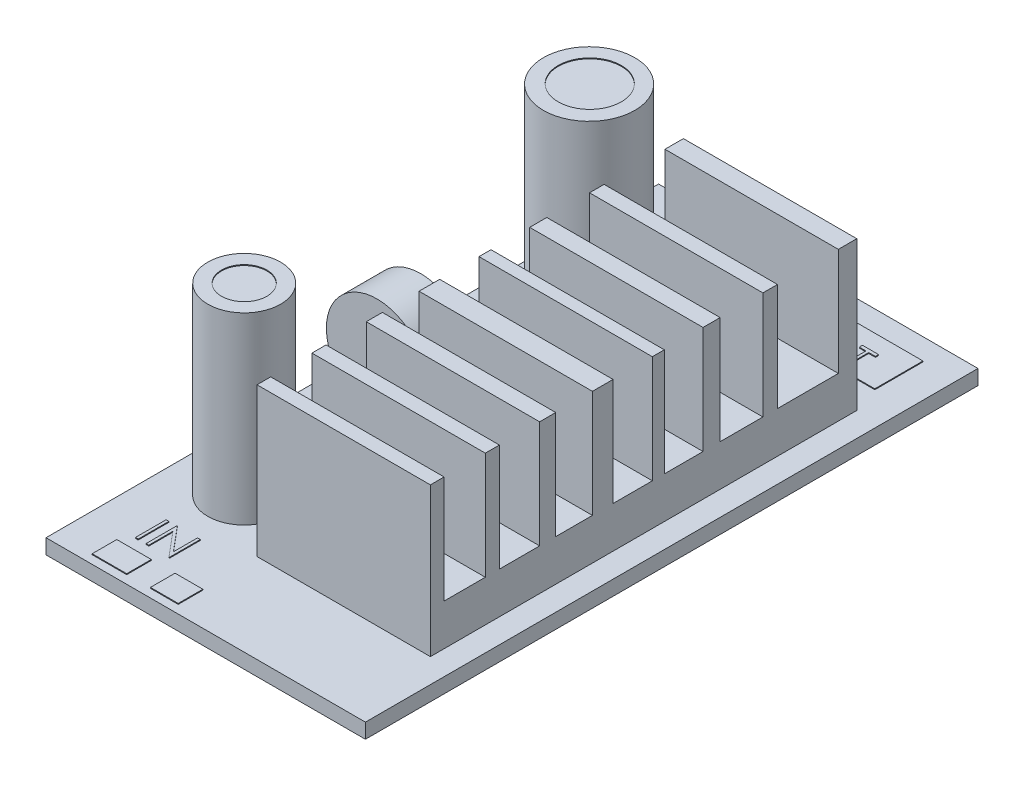
from build123d import *

# Parameters (mm, degrees)
SKETCH1_W            = 36.5
SKETCH1_H            = 70
BOSS_EXTRUDE1_DEPTH  = 1.7
SKETCH2_W            = 19.810620686
SKETCH2_H            = 48.723418446
BOSS_EXTRUDE2_DEPTH  = 17
SKETCH3_W            = 6.953051931
SKETCH3_H            = 17.871067358
SKETCH3_W_2          = 4.884375323
SKETCH3_W_3          = 4.424669411
SKETCH3_W_4          = 4.492569906
SKETCH3_W_5          = 4.194816454
SKETCH3_W_6          = 4.597059127
SKETCH3_W_7          = 4.711985605
CUT_EXTRUDE1_DEPTH   = 28
SKETCH4_R            = 5.221404291
SKETCH4_R_2          = 4.164394739
BOSS_EXTRUDE3_DEPTH  = 21
SKETCH5_R            = 3.607238236
SKETCH5_R_2          = 2.597429553
CUT_EXTRUDE2_DEPTH   = 0.1
SKETCH6_W            = 3.944670861
SKETCH6_H            = 4.098359336
SKETCH6_W_2          = 3.739752895
SKETCH6_H_2          = 4.098359337
SKETCH6_H_3          = 2.810169011
SKETCH6_W_3          = 3.171545661
BOSS_EXTRUDE4_DEPTH  = 0.1
SKETCH7_W            = 0.314102564
SKETCH7_H            = 3.5
BOSS_EXTRUDE5_DEPTH  = 0.1
BOSS_EXTRUDE6_DEPTH  = 0.1
SKETCH9_W            = 13.236826134
SKETCH9_H            = 5.502950191
BOSS_EXTRUDE7_DEPTH  = 0.1
BOSS_EXTRUDE8_DEPTH  = 0.1
BOSS_EXTRUDE10_DEPTH = 5


with BuildPart() as part:
    # Sketch1 → Boss-Extrude1 (new body)
    with BuildSketch(Plane(origin=(0, 0, 0), x_dir=(1, 0, 0), z_dir=(0, 1, 0))):
        with Locations((-3.148767606, -0.556338028)):
            Rectangle(SKETCH1_W, SKETCH1_H)
    extrude(amount=BOSS_EXTRUDE1_DEPTH)

    # Sketch2 → Boss-Extrude2 (add)
    with BuildSketch(Plane(origin=(0, 1.7, 0), x_dir=(1, 0, 0), z_dir=(0, 1, 0))):
        with Locations((2.428546777, -1.002523179)):
            Rectangle(SKETCH2_W, SKETCH2_H)
    extrude(amount=BOSS_EXTRUDE2_DEPTH)

    # Sketch3 → Cut-Extrude1 (cut)
    with BuildSketch(Plane.ZY.offset(7.476763566)):
        with Locations((-17.774435243, 15.354908485)):
            Rectangle(SKETCH3_W, SKETCH3_H)
        with Locations((-10.189287682, 15.354908485)):
            Rectangle(SKETCH3_W_2, SKETCH3_H)
        with Locations((-3.581015187, 15.354908485)):
            Rectangle(SKETCH3_W_3, SKETCH3_H)
        with Locations((2.246284953, 15.354908485)):
            Rectangle(SKETCH3_W_4, SKETCH3_H)
        with Locations((8.945970936, 15.354908485)):
            Rectangle(SKETCH3_W_5, SKETCH3_H)
        with Locations((15.180732378, 15.354908485)):
            Rectangle(SKETCH3_W_6, SKETCH3_H)
        with Locations((21.444225439, 15.354908485)):
            Rectangle(SKETCH3_W_7, SKETCH3_H)
    extrude(amount=-CUT_EXTRUDE1_DEPTH, mode=Mode.SUBTRACT)

    # Sketch4 → Boss-Extrude3 (add)
    with BuildSketch(Plane(origin=(0, 1.7, 0), x_dir=(1, 0, 0), z_dir=(0, 1, 0))):
        with Locations((-14.266214275, 19.373265365)):
            Circle(SKETCH4_R)
        with Locations((-14.266214275, -20.039756271)):
            Circle(SKETCH4_R_2)
    extrude(amount=BOSS_EXTRUDE3_DEPTH)

    # Sketch5 → Cut-Extrude2 (cut)
    with BuildSketch(Plane(origin=(0, 22.7, 0), x_dir=(1, 0, 0), z_dir=(0, 1, 0))):
        with Locations((-14.266214275, 19.447629557)):
            Circle(SKETCH5_R)
        with Locations((-14.266214275, -20.039756271)):
            Circle(SKETCH5_R_2)
    extrude(amount=-CUT_EXTRUDE2_DEPTH, mode=Mode.SUBTRACT)

    # Sketch6 → Boss-Extrude4 (add)
    with BuildSketch(Plane(origin=(0, 1.7, 0), x_dir=(1, 0, 0), z_dir=(0, 1, 0))):
        with Locations((-15.10212375, 30.400788251)):
            Rectangle(SKETCH6_W, SKETCH6_H)
        with Locations((-8.54474881, 30.298329268)):
            Rectangle(SKETCH6_W_2, SKETCH6_H_2)
        with Locations((-15.10212375, -33.198217184)):
            Rectangle(SKETCH6_W, SKETCH6_H_3)
        with Locations((-8.828852428, -33.198217184)):
            Rectangle(SKETCH6_W_3, SKETCH6_H_3)
    extrude(amount=BOSS_EXTRUDE4_DEPTH)

    # Sketch7 → Boss-Extrude5 (add)
    with BuildSketch(Plane(origin=(0, 1.7, 0), x_dir=(1, 0, 0), z_dir=(0, 1, 0))):
        with Locations((-16.057613637, -28.766806996)):
            Rectangle(SKETCH7_W, SKETCH7_H)
        Polygon((-15.003126458, -30.516806996), (-15.003126458, -27.016806996), (-14.937221009, -27.016806996), (-12.62492133, -29.771514528), (-12.62492133, -27.016806996), (-12.310818765, -27.016806996), (-12.310818765, -30.516806996), (-12.382333188, -30.516806996), (-14.689023894, -27.76840956), (-14.689023894, -30.516806996), align=None)
    extrude(amount=BOSS_EXTRUDE5_DEPTH)

    # Sketch8 → Boss-Extrude6 (add)
    with BuildSketch(Plane(origin=(0, 1.7, 0), x_dir=(1, 0, 0), z_dir=(0, 1, 0))):
        with BuildLine():
            add(Edge.make_bspline(
                [(-15.055999829, 28.184413247), (-14.991191723, 28.182771767), (-14.863903256, 28.179547766), (-14.676828359, 28.154868663), (-14.498233263, 28.112173273), (-14.326663124, 28.05531029), (-14.164170148, 27.979455905), (-14.009531255, 27.887770757), (-13.863114382, 27.779294298), (-13.726893, 27.654865071), (-13.60223605, 27.519481617), (-13.492410164, 27.375003707), (-13.40036787, 27.222304905), (-13.324782083, 27.061844074), (-13.265483473, 26.893984106), (-13.224564429, 26.717830103), (-13.198426279, 26.534523413), (-13.195370502, 26.409496549), (-13.193820342, 26.3460719)],
                knots=[0, 0, 0, 0, 0.000194393, 0.000381804, 0.00056479, 0.000744601, 0.000923091, 0.001101652, 0.001283106, 0.001468738, 0.001654324, 0.001834514, 0.002012231, 0.002188181, 0.002365797, 0.002545211, 0.002729936, 0.002920126, 0.002920126, 0.002920126, 0.002920126], degree=3))
            add(Edge.make_bspline(
                [(-13.193820342, 26.3460719), (-13.195370275, 26.283114454), (-13.198425371, 26.159018034), (-13.224594149, 25.976874589), (-13.265635149, 25.801783893), (-13.324231415, 25.63403824), (-13.399456893, 25.473460676), (-13.492112064, 25.320473723), (-13.601253275, 25.175027224), (-13.725460126, 25.038714559), (-13.860861168, 24.913717088), (-14.006091435, 24.804798213), (-14.157884755, 24.711074088), (-14.318194463, 24.636290414), (-14.4848945, 24.576518494), (-14.659476823, 24.535765864), (-14.841123377, 24.50947882), (-14.964994381, 24.506460304), (-15.027954957, 24.504926067)],
                knots=[0, 0, 0, 0, 0.000188789, 0.000372126, 0.000550857, 0.00072758, 0.000904164, 0.001081881, 0.001263191, 0.001448823, 0.00163441, 0.001815159, 0.001992641, 0.002168591, 0.002344885, 0.002522934, 0.002705576, 0.002894365, 0.002894365, 0.002894365, 0.002894365], degree=3))
            add(Edge.make_bspline(
                [(-15.027954957, 24.504926067), (-15.091379276, 24.506475454), (-15.216405492, 24.509529708), (-15.399942528, 24.535711113), (-15.576220272, 24.576652416), (-15.744734623, 24.635161853), (-15.905579552, 24.710779083), (-16.059069635, 24.802983462), (-16.204588782, 24.912390604), (-16.340930529, 25.036557178), (-16.465679727, 25.17172873), (-16.574439103, 25.316562985), (-16.666664216, 25.468218442), (-16.742027548, 25.627115966), (-16.801692008, 25.792487409), (-16.842396826, 25.965435886), (-16.868732778, 26.144975392), (-16.871767624, 26.26721829), (-16.873307521, 26.329244977)],
                knots=[0, 0, 0, 0, 0.00019019, 0.000374915, 0.000555011, 0.000732396, 0.00090898, 0.001087298, 0.001268608, 0.00145424, 0.001639827, 0.001819595, 0.001996712, 0.002171394, 0.002346367, 0.002523053, 0.002703612, 0.002889599, 0.002889599, 0.002889599, 0.002889599], degree=3))
            add(Edge.make_bspline(
                [(-16.873307521, 26.329244977), (-16.872772886, 26.370877646), (-16.87171036, 26.45361777), (-16.858918667, 26.57648437), (-16.840356966, 26.697375028), (-16.813755053, 26.815945976), (-16.778963386, 26.931906961), (-16.737911359, 27.046057723), (-16.687771514, 27.157241447), (-16.631090866, 27.265984839), (-16.567829058, 27.370592745), (-16.497953308, 27.469472328), (-16.42391794, 27.563453325), (-16.342754546, 27.650100328), (-16.257138101, 27.731933985), (-16.165679723, 27.807696702), (-16.068937478, 27.878071653), (-15.966495099, 27.941491994), (-15.860876824, 27.998851129), (-15.752000046, 28.04807298), (-15.641343474, 28.090319041), (-15.528388827, 28.124559866), (-15.413436054, 28.151591902), (-15.29623427, 28.169999256), (-15.176876844, 28.182823574), (-15.096465525, 28.183881076), (-15.055999829, 28.184413247)],
                knots=[0, 0, 0, 0, 0.000124849, 0.000248123, 0.000370193, 0.00049164, 0.000612319, 0.000733199, 0.000855287, 0.000977905, 0.001100913, 0.001221706, 0.001340948, 0.001459521, 0.001577551, 0.001696047, 0.001815534, 0.001936153, 0.002057243, 0.002175846, 0.002294342, 0.002412335, 0.002529682, 0.00264829, 0.002768075, 0.00288942, 0.00288942, 0.00288942, 0.00288942], degree=3))
        make_face()
        with BuildLine():
            add(Edge.make_bspline(
                [(-15.04057515, 27.825438888), (-15.073789783, 27.825033997), (-15.139901516, 27.824228088), (-15.238186052, 27.813612372), (-15.335177986, 27.798482483), (-15.430897348, 27.776900962), (-15.524943638, 27.74749691), (-15.618193479, 27.713656001), (-15.709796533, 27.672434911), (-15.799450391, 27.625862206), (-15.886365466, 27.574313286), (-15.968378167, 27.517341519), (-16.045700811, 27.456282964), (-16.118144078, 27.390995127), (-16.18549525, 27.321145525), (-16.249079952, 27.247793089), (-16.306349533, 27.168841198), (-16.35883511, 27.086430791), (-16.40580295, 27.00066921), (-16.447568305, 26.912459348), (-16.481732314, 26.821081661), (-16.50959469, 26.727527503), (-16.532694501, 26.631945044), (-16.547328425, 26.533609195), (-16.558060784, 26.433014083), (-16.55882063, 26.365032229), (-16.559204957, 26.330647221)],
                knots=[0, 0, 0, 0, 9.9599e-05, 0.000198245, 0.000296222, 0.00039402, 0.00049227, 0.000591646, 0.000691452, 0.000793368, 0.000894612, 0.000994383, 0.001092713, 0.00119001, 0.001286696, 0.001383657, 0.001480979, 0.001579008, 0.001676595, 0.001774142, 0.001871547, 0.001968922, 0.002066879, 0.00216624, 0.00226698, 0.002370083, 0.002370083, 0.002370083, 0.002370083], degree=3))
            add(Edge.make_bspline(
                [(-16.559204957, 26.330647221), (-16.557930095, 26.280085), (-16.555422048, 26.18061347), (-16.533464477, 26.034845326), (-16.499642503, 25.89475704), (-16.449785137, 25.76111513), (-16.387434522, 25.632770848), (-16.310407632, 25.510862743), (-16.219148546, 25.395357868), (-16.115485019, 25.2870626), (-16.002162313, 25.188216795), (-15.881829583, 25.101453387), (-15.755775975, 25.028043137), (-15.623672773, 24.968238064), (-15.486225234, 24.920848327), (-15.342547683, 24.888369695), (-15.193597223, 24.86699424), (-15.092066568, 24.864941484), (-15.04057515, 24.863900426)],
                knots=[0, 0, 0, 0, 0.000151605, 0.000298253, 0.000441263, 0.000583229, 0.000725274, 0.000868635, 0.001014928, 0.001166177, 0.001317744, 0.00146543, 0.001610576, 0.001754594, 0.001899821, 0.002045914, 0.002195936, 0.002350312, 0.002350312, 0.002350312, 0.002350312], degree=3))
            add(Edge.make_bspline(
                [(-15.04057515, 24.863900426), (-15.005965648, 24.86437593), (-14.937324612, 24.865318998), (-14.835229089, 24.874817675), (-14.734972878, 24.890049545), (-14.636696598, 24.9119802), (-14.540511786, 24.939427407), (-14.446016983, 24.972035135), (-14.354218693, 25.012716338), (-14.263958855, 25.05766429), (-14.177562613, 25.108904447), (-14.095087081, 25.163942597), (-14.018611101, 25.224911218), (-13.94622203, 25.28922903), (-13.878594341, 25.358192878), (-13.816185357, 25.4317131), (-13.759205224, 25.510253757), (-13.706739578, 25.592539163), (-13.659936315, 25.678535416), (-13.619157216, 25.767065094), (-13.5845611, 25.857910203), (-13.556632595, 25.951201775), (-13.534747134, 26.046762623), (-13.519667214, 26.144720701), (-13.509118775, 26.244880044), (-13.508323698, 26.3126239), (-13.507922906, 26.346773022)],
                knots=[0, 0, 0, 0, 0.000103804, 0.000205874, 0.000307314, 0.000407849, 0.000507719, 0.000607281, 0.000707445, 0.000808723, 0.000909609, 0.001008589, 0.001105934, 0.001202762, 0.001298946, 0.001395452, 0.001491794, 0.001589823, 0.001688026, 0.001785277, 0.001882027, 0.001979402, 0.0020772, 0.002175869, 0.002276609, 0.002379011, 0.002379011, 0.002379011, 0.002379011], degree=3))
            add(Edge.make_bspline(
                [(-13.507922906, 26.346773022), (-13.508324019, 26.380688527), (-13.509119701, 26.447966177), (-13.519662175, 26.547426995), (-13.534763066, 26.644680207), (-13.556525774, 26.73934401), (-13.584575927, 26.831442535), (-13.619163258, 26.920889282), (-13.659948557, 27.008017477), (-13.706756782, 27.092611774), (-13.759372605, 27.173786512), (-13.816866848, 27.251388925), (-13.880232196, 27.323961666), (-13.947658221, 27.39329636), (-14.020829107, 27.45791425), (-14.099413401, 27.51783677), (-14.182457079, 27.574510045), (-14.270384314, 27.625635607), (-14.361128268, 27.672849839), (-14.454242226, 27.713300842), (-14.548671325, 27.747672962), (-14.644175438, 27.776989927), (-14.741558416, 27.798397957), (-14.840162245, 27.813626007), (-14.939850503, 27.824224393), (-15.006893723, 27.825032771), (-15.04057515, 27.825438888)],
                knots=[0, 0, 0, 0, 0.000101701, 0.000201743, 0.00029972, 0.000396835, 0.000492868, 0.000588308, 0.000684288, 0.000781261, 0.000878109, 0.000974304, 0.001070733, 0.001166917, 0.001264269, 0.001363274, 0.001463228, 0.001565678, 0.001668217, 0.001769947, 0.001869982, 0.001969573, 0.002069423, 0.002168785, 0.002268827, 0.002369827, 0.002369827, 0.002369827, 0.002369827], degree=3))
        make_face(mode=Mode.SUBTRACT)
        with BuildLine():
            Line((-12.475871624, 28.094669657), (-12.16176906, 28.094669657))
            Line((-12.16176906, 28.094669657), (-12.16176906, 25.997614368))
            add(Edge.make_bspline(
                [(-12.16176906, 25.997614368), (-12.161815804, 25.967933633), (-12.161904509, 25.911609322), (-12.161311995, 25.831441021), (-12.159652626, 25.760168562), (-12.158606467, 25.697517215), (-12.156279133, 25.643774467), (-12.154381086, 25.598649156), (-12.15194053, 25.562354954), (-12.149007412, 25.541174028), (-12.147746624, 25.532069497)],
                knots=[0, 0, 0, 0, 8.9042e-05, 0.000168973, 0.000240502, 0.000302917, 0.000356945, 0.000401866, 0.000438432, 0.000465999, 0.000465999, 0.000465999, 0.000465999], degree=3))
            add(Edge.make_bspline(
                [(-12.147746624, 25.532069497), (-12.142569165, 25.499222733), (-12.132505979, 25.435380004), (-12.106859601, 25.344471722), (-12.0710421, 25.262540264), (-12.028599057, 25.187028973), (-11.972666446, 25.120039613), (-11.905662911, 25.05832796), (-11.824485142, 25.004356155), (-11.734224537, 24.955005344), (-11.636939299, 24.915340261), (-11.537528033, 24.885346897), (-11.437485054, 24.867067997), (-11.370508888, 24.864951458), (-11.337249829, 24.863900426)],
                knots=[0, 0, 0, 0, 9.971e-05, 0.000193801, 0.000282365, 0.000367504, 0.000452699, 0.000543015, 0.000639862, 0.000744331, 0.000851226, 0.000954377, 0.001055468, 0.001155185, 0.001155185, 0.001155185, 0.001155185], degree=3))
            add(Edge.make_bspline(
                [(-11.337249829, 24.863900426), (-11.308696089, 24.864974276), (-11.251753527, 24.867115775), (-11.167147096, 24.880377206), (-11.084746988, 24.904277771), (-11.004146308, 24.93511753), (-10.928595323, 24.975865121), (-10.858051881, 25.02293596), (-10.795087947, 25.078146836), (-10.737629949, 25.139247181), (-10.687595013, 25.208186981), (-10.644223872, 25.283465119), (-10.608697942, 25.366214466), (-10.591154417, 25.424368888), (-10.582141656, 25.454244977)],
                knots=[0, 0, 0, 0, 8.5678e-05, 0.00017086, 0.000256092, 0.000342674, 0.000429242, 0.000513055, 0.000596556, 0.000679898, 0.000764179, 0.00085149, 0.000940054, 0.001033621, 0.001033621, 0.001033621, 0.001033621], degree=3))
            add(Edge.make_bspline(
                [(-10.582141656, 25.454244977), (-10.579141531, 25.466593552), (-10.572456043, 25.494111152), (-10.566208998, 25.540632442), (-10.559702472, 25.595521806), (-10.555187902, 25.659173619), (-10.550786682, 25.731374592), (-10.548153609, 25.812500849), (-10.546936576, 25.90225781), (-10.546573896, 25.964894972), (-10.546384445, 25.997614368)],
                knots=[0, 0, 0, 0, 3.81e-05, 8.4902e-05, 0.000140649, 0.000203941, 0.000276279, 0.000357657, 0.000447412, 0.000545571, 0.000545571, 0.000545571, 0.000545571], degree=3))
            Line((-10.546384445, 25.997614368), (-10.546384445, 28.094669657))
            Line((-10.546384445, 28.094669657), (-10.23228188, 28.094669657))
            Line((-10.23228188, 28.094669657), (-10.23228188, 25.980787445))
            add(Edge.make_bspline(
                [(-10.23228188, 25.980787445), (-10.232536001, 25.942689066), (-10.233031932, 25.868337763), (-10.237332509, 25.759386404), (-10.244189509, 25.656033423), (-10.253877597, 25.558264927), (-10.2667146, 25.466430767), (-10.28098982, 25.379725999), (-10.299169353, 25.298773007), (-10.320402754, 25.222940589), (-10.344676302, 25.150755075), (-10.376117451, 25.082246461), (-10.411541951, 25.015332061), (-10.453556604, 24.951023952), (-10.500767986, 24.889037399), (-10.554219667, 24.829748324), (-10.612143828, 24.772209278), (-10.675503388, 24.717896212), (-10.743253913, 24.668087535), (-10.81519387, 24.624289764), (-10.89077064, 24.587266146), (-10.969787766, 24.556790222), (-11.052278969, 24.533875623), (-11.138246329, 24.516800467), (-11.227885522, 24.507098169), (-11.288850178, 24.505656239), (-11.319721784, 24.504926067)],
                knots=[0, 0, 0, 0, 0.000114291, 0.000223047, 0.000327049, 0.000424998, 0.000517708, 0.000605194, 0.000688542, 0.000766455, 0.0008414, 0.000916717, 0.000992315, 0.001068354, 0.001146882, 0.001225836, 0.001307639, 0.001391671, 0.001475952, 0.001559641, 0.001643989, 0.001728103, 0.001813335, 0.001900511, 0.00199079, 0.002083404, 0.002083404, 0.002083404, 0.002083404], degree=3))
            add(Edge.make_bspline(
                [(-11.319721784, 24.504926067), (-11.353390887, 24.505710832), (-11.419449546, 24.507250539), (-11.516787613, 24.516073289), (-11.610101809, 24.532691683), (-11.700377686, 24.553851627), (-11.786386184, 24.583035364), (-11.869279628, 24.617133489), (-11.947638309, 24.65901075), (-12.022733438, 24.705604143), (-12.092558194, 24.758028781), (-12.156655597, 24.815168955), (-12.215131467, 24.876109332), (-12.267000164, 24.941509698), (-12.313121048, 25.010861405), (-12.352851262, 25.084360645), (-12.386964506, 25.161978961), (-12.404571073, 25.215932161), (-12.413471784, 25.243207317)],
                knots=[0, 0, 0, 0, 0.000101022, 0.000198206, 0.000292839, 0.000385177, 0.00047608, 0.000565014, 0.000653769, 0.000742283, 0.000829923, 0.000915339, 0.000999643, 0.001082971, 0.00116542, 0.001249186, 0.001333332, 0.001419362, 0.001419362, 0.001419362, 0.001419362], degree=3))
            add(Edge.make_bspline(
                [(-12.413471784, 25.243207317), (-12.418648942, 25.261839892), (-12.429878314, 25.30225436), (-12.441903611, 25.369140849), (-12.452012693, 25.446155767), (-12.461518251, 25.533304385), (-12.467127209, 25.630654252), (-12.472044648, 25.738163168), (-12.475906267, 25.855961129), (-12.475883494, 25.938015645), (-12.475871624, 25.980787445)],
                knots=[0, 0, 0, 0, 5.799e-05, 0.000125782, 0.000203619, 0.000291034, 0.000388694, 0.000496078, 0.000613919, 0.000742226, 0.000742226, 0.000742226, 0.000742226], degree=3))
            Line((-12.475871624, 25.980787445), (-12.475871624, 28.094669657))
        make_face()
        Polygon((-9.738692137, 27.735695298), (-9.738692137, 28.094669657), (-7.898948547, 28.094669657), (-7.898948547, 27.735695298), (-8.66176906, 27.735695298), (-8.66176906, 24.594669657), (-8.975871624, 24.594669657), (-8.975871624, 27.735695298), align=None)
    extrude(amount=BOSS_EXTRUDE6_DEPTH)

    # Sketch9 → Boss-Extrude7 (add)
    with BuildSketch(Plane(origin=(0, 1.7, 0), x_dir=(1, 0, 0), z_dir=(0, 1, 0))):
        with Locations((4.696654626, 29.189338679)):
            Rectangle(SKETCH9_W, SKETCH9_H)
    extrude(amount=BOSS_EXTRUDE7_DEPTH)

    # Sketch10 → Boss-Extrude8 (add)
    with BuildSketch(Plane(origin=(0, 1.8, 0), x_dir=(1, 0, 0), z_dir=(0, 1, 0))):
        with BuildLine():
            Line((-0.283213424, 29.937863583), (0.403184813, 29.937863583))
            add(Edge.make_bspline(
                [(0.403184813, 29.937863583), (0.450395719, 29.937811687), (0.540853912, 29.937712252), (0.670568967, 29.934697506), (0.788378699, 29.930670814), (0.89402908, 29.92508892), (0.987845178, 29.91849233), (1.069402478, 29.909240291), (1.139342034, 29.899579995), (1.181248483, 29.889758589), (1.200360293, 29.885279449)],
                knots=[0, 0, 0, 0, 0.000141628, 0.000271366, 0.00038923, 0.000495248, 0.00058876, 0.000671296, 0.000741499, 0.00080036, 0.00080036, 0.00080036, 0.00080036], degree=3))
            add(Edge.make_bspline(
                [(1.200360293, 29.885279449), (1.224553827, 29.878657499), (1.272370804, 29.865569637), (1.341271848, 29.839355914), (1.406825693, 29.808273748), (1.469257251, 29.772849809), (1.527799335, 29.731564244), (1.583325376, 29.686090627), (1.635345356, 29.635379058), (1.683566748, 29.579998318), (1.727851545, 29.520878108), (1.765981228, 29.457135878), (1.797908455, 29.389844575), (1.825291727, 29.319051004), (1.845000181, 29.24416068), (1.859847081, 29.165693968), (1.869270708, 29.083659278), (1.87017327, 29.02759941), (1.870632729, 28.9990615)],
                knots=[0, 0, 0, 0, 7.5216e-05, 0.00014866, 0.000220794, 0.000292713, 0.000363707, 0.000435434, 0.000507823, 0.000581364, 0.000655543, 0.000729131, 0.000803767, 0.000878771, 0.000956497, 0.001035702, 0.001118238, 0.001203821, 0.001203821, 0.001203821, 0.001203821], degree=3))
            add(Edge.make_bspline(
                [(1.870632729, 28.9990615), (1.870211305, 28.970283723), (1.869386759, 28.913978059), (1.859490473, 28.831605271), (1.846160282, 28.752886881), (1.825663229, 28.67799743), (1.798817556, 28.60738166), (1.767325503, 28.539960428), (1.729341973, 28.476880756), (1.685697143, 28.417913638), (1.637145549, 28.363003726), (1.583892611, 28.312548932), (1.526153318, 28.266844593), (1.46411117, 28.22578825), (1.397161321, 28.19033197), (1.326319168, 28.158574665), (1.250968951, 28.131903605), (1.198826437, 28.117873543), (1.172315422, 28.110740186)],
                knots=[0, 0, 0, 0, 8.6284e-05, 0.00016882, 0.000248587, 0.000325638, 0.000401297, 0.000474998, 0.000548586, 0.000621785, 0.0006948, 0.0007682, 0.000841564, 0.000915458, 0.000991056, 0.00106858, 0.00114819, 0.001230532, 0.001230532, 0.001230532, 0.001230532], degree=3))
            add(Edge.make_bspline(
                [(1.172315422, 28.110740186), (1.150388088, 28.106077205), (1.10233306, 28.095858011), (1.023190338, 28.084449554), (0.931044952, 28.074711953), (0.826022672, 28.067410816), (0.708217767, 28.061160447), (0.57756651, 28.056192353), (0.433812433, 28.053462499), (0.333541189, 28.053321707), (0.28118962, 28.053248199)],
                knots=[0, 0, 0, 0, 6.7238e-05, 0.000147357, 0.000239727, 0.000345177, 0.000463135, 0.000593636, 0.000737393, 0.000894446, 0.000894446, 0.000894446, 0.000894446], degree=3))
            Line((0.28118962, 28.053248199), (0.03088914, 28.053248199))
            Line((0.03088914, 28.053248199), (0.03088914, 26.437863583))
            Line((0.03088914, 26.437863583), (-0.283213424, 26.437863583))
            Line((-0.283213424, 26.437863583), (-0.283213424, 29.937863583))
        make_face()
        with BuildLine():
            Line((0.03088914, 29.578889224), (0.03088914, 28.412222558))
            Line((0.03088914, 28.412222558), (0.643669588, 28.404510218))
            add(Edge.make_bspline(
                [(0.643669588, 28.404510218), (0.673589514, 28.404494754), (0.731349314, 28.404464902), (0.814785537, 28.408450126), (0.892194825, 28.413050658), (0.9633394, 28.419786582), (1.028251334, 28.429307839), (1.087038863, 28.438919577), (1.139246146, 28.45282494), (1.200345348, 28.471548009), (1.268428695, 28.503480625), (1.342496244, 28.549830515), (1.40526683, 28.608911223), (1.459585127, 28.675339054), (1.502691005, 28.749238184), (1.534246997, 28.82830712), (1.552788155, 28.91173497), (1.555274348, 28.968823109), (1.556530165, 28.997659256)],
                knots=[0, 0, 0, 0, 8.9746e-05, 0.000173253, 0.000250533, 0.00032239, 0.000387534, 0.00044736, 0.000500926, 0.000549486, 0.000638903, 0.000725641, 0.000810488, 0.000896226, 0.000982324, 0.00106604, 0.001150757, 0.001237226, 0.001237226, 0.001237226, 0.001237226], degree=3))
            add(Edge.make_bspline(
                [(1.556530165, 28.997659256), (1.555267519, 29.02579777), (1.552757534, 29.081733652), (1.534101671, 29.163712413), (1.502752357, 29.241948117), (1.459295762, 29.314921202), (1.406554632, 29.381110006), (1.345255289, 29.438607133), (1.275542028, 29.484828836), (1.210693797, 29.514662118), (1.153092611, 29.532877393), (1.103060651, 29.545622234), (1.046569976, 29.55579784), (0.983602197, 29.564037343), (0.914645363, 29.571090804), (0.839107048, 29.575876781), (0.757273405, 29.578678237), (0.700462834, 29.578817193), (0.671013338, 29.578889224)],
                knots=[0, 0, 0, 0, 8.4371e-05, 0.000167719, 0.000250783, 0.000336277, 0.000421575, 0.000503926, 0.000587348, 0.000671427, 0.000717102, 0.000768457, 0.000826213, 0.000889178, 0.000958942, 0.001034123, 0.001116202, 0.001204546, 0.001204546, 0.001204546, 0.001204546], degree=3))
            Line((0.671013338, 29.578889224), (0.03088914, 29.578889224))
        make_face(mode=Mode.SUBTRACT)
        with BuildLine():
            add(Edge.make_bspline(
                [(4.22640196, 30.027607173), (4.291210066, 30.025965694), (4.418498533, 30.022741693), (4.605573431, 29.998062589), (4.784168526, 29.955367199), (4.955738665, 29.898504217), (5.118231641, 29.822649831), (5.272870534, 29.730964683), (5.419287408, 29.622488224), (5.555508789, 29.498058997), (5.68016574, 29.362675544), (5.789991626, 29.218197633), (5.88203392, 29.065498831), (5.957619707, 28.905038), (6.016918316, 28.737178033), (6.05783736, 28.56102403), (6.08397551, 28.37771734), (6.087031288, 28.252690475), (6.088581447, 28.189265827)],
                knots=[0, 0, 0, 0, 0.000194393, 0.000381804, 0.00056479, 0.000744601, 0.000923091, 0.001101652, 0.001283106, 0.001468738, 0.001654324, 0.001834514, 0.002012231, 0.002188181, 0.002365797, 0.002545211, 0.002729936, 0.002920126, 0.002920126, 0.002920126, 0.002920126], degree=3))
            add(Edge.make_bspline(
                [(6.088581447, 28.189265827), (6.087031515, 28.126308381), (6.083976418, 28.00221196), (6.057807641, 27.820068516), (6.016766641, 27.644977819), (5.958170375, 27.477232167), (5.882944896, 27.316654603), (5.790289725, 27.163667649), (5.681148514, 27.018221151), (5.556941663, 26.881908485), (5.421540621, 26.756911015), (5.276310354, 26.647992139), (5.124517034, 26.554268014), (4.964207326, 26.47948434), (4.797507289, 26.41971242), (4.622924966, 26.37895979), (4.441278412, 26.352672747), (4.317407408, 26.349654231), (4.254446832, 26.348119994)],
                knots=[0, 0, 0, 0, 0.000188789, 0.000372126, 0.000550857, 0.00072758, 0.000904164, 0.001081881, 0.001263191, 0.001448823, 0.00163441, 0.001815159, 0.001992641, 0.002168591, 0.002344885, 0.002522934, 0.002705576, 0.002894365, 0.002894365, 0.002894365, 0.002894365], degree=3))
            add(Edge.make_bspline(
                [(4.254446832, 26.348119994), (4.191022513, 26.34966938), (4.065996297, 26.352723634), (3.882459262, 26.378905039), (3.706181518, 26.419846343), (3.537667167, 26.478355779), (3.376822237, 26.55397301), (3.223332154, 26.646177389), (3.077813007, 26.75558453), (2.941471261, 26.879751105), (2.816722062, 27.014922657), (2.707962687, 27.159756912), (2.615737573, 27.311412368), (2.540374241, 27.470309893), (2.480709782, 27.635681335), (2.440004963, 27.808629813), (2.413669011, 27.988169319), (2.410634165, 28.110412217), (2.409094268, 28.172438904)],
                knots=[0, 0, 0, 0, 0.00019019, 0.000374915, 0.000555011, 0.000732396, 0.00090898, 0.001087298, 0.001268608, 0.00145424, 0.001639827, 0.001819595, 0.001996712, 0.002171394, 0.002346367, 0.002523053, 0.002703612, 0.002889599, 0.002889599, 0.002889599, 0.002889599], degree=3))
            add(Edge.make_bspline(
                [(2.409094268, 28.172438904), (2.409628903, 28.214071573), (2.41069143, 28.296811696), (2.423483122, 28.419678297), (2.442044823, 28.540568954), (2.468646736, 28.659139902), (2.503438403, 28.775100887), (2.54449043, 28.88925165), (2.594630276, 29.000435374), (2.651310924, 29.109178765), (2.714572732, 29.213786671), (2.784448481, 29.312666254), (2.85848385, 29.406647251), (2.939647243, 29.493294255), (3.025263688, 29.575127911), (3.116722067, 29.650890628), (3.213464311, 29.721265579), (3.315906691, 29.78468592), (3.421524966, 29.842045055), (3.530401743, 29.891266906), (3.641058315, 29.933512967), (3.754012963, 29.967753793), (3.868965735, 29.994785829), (3.986167519, 30.013193182), (4.105524946, 30.0260175), (4.185936265, 30.027075002), (4.22640196, 30.027607173)],
                knots=[0, 0, 0, 0, 0.000124849, 0.000248123, 0.000370193, 0.00049164, 0.000612319, 0.000733199, 0.000855287, 0.000977905, 0.001100913, 0.001221706, 0.001340948, 0.001459521, 0.001577551, 0.001696047, 0.001815534, 0.001936153, 0.002057243, 0.002175846, 0.002294342, 0.002412335, 0.002529682, 0.00264829, 0.002768075, 0.00288942, 0.00288942, 0.00288942, 0.00288942], degree=3))
        make_face()
        with BuildLine():
            add(Edge.make_bspline(
                [(4.24182664, 29.668632814), (4.208612006, 29.668227924), (4.142500273, 29.667422014), (4.044215737, 29.656806298), (3.947223803, 29.64167641), (3.851504441, 29.620094889), (3.757458152, 29.590690836), (3.66420831, 29.556849928), (3.572605256, 29.515628837), (3.482951399, 29.469056133), (3.396036323, 29.417507212), (3.314023622, 29.360535445), (3.236700978, 29.299476891), (3.164257711, 29.234189053), (3.096906539, 29.164339452), (3.033321838, 29.090987015), (2.976052256, 29.012035124), (2.923566679, 28.929624718), (2.876598839, 28.843863136), (2.834833484, 28.755653274), (2.800669475, 28.664275587), (2.772807099, 28.57072143), (2.749707288, 28.47513897), (2.735073364, 28.376803121), (2.724341005, 28.276208009), (2.723581159, 28.208226155), (2.723196832, 28.173841147)],
                knots=[0, 0, 0, 0, 9.9599e-05, 0.000198245, 0.000296222, 0.00039402, 0.00049227, 0.000591646, 0.000691452, 0.000793368, 0.000894612, 0.000994383, 0.001092713, 0.00119001, 0.001286696, 0.001383657, 0.001480979, 0.001579008, 0.001676595, 0.001774142, 0.001871547, 0.001968922, 0.002066879, 0.00216624, 0.00226698, 0.002370083, 0.002370083, 0.002370083, 0.002370083], degree=3))
            add(Edge.make_bspline(
                [(2.723196832, 28.173841147), (2.724471694, 28.123278927), (2.726979742, 28.023807396), (2.748937312, 27.878039252), (2.782759286, 27.737950966), (2.832616653, 27.604309057), (2.894967267, 27.475964774), (2.971994158, 27.354056669), (3.063253243, 27.238551795), (3.16691677, 27.130256526), (3.280239476, 27.031410722), (3.400572206, 26.944647313), (3.526625814, 26.871237063), (3.658729017, 26.811431991), (3.796176556, 26.764042253), (3.939854107, 26.731563622), (4.088804566, 26.710188167), (4.190335221, 26.708135411), (4.24182664, 26.707094353)],
                knots=[0, 0, 0, 0, 0.000151605, 0.000298253, 0.000441263, 0.000583229, 0.000725274, 0.000868635, 0.001014928, 0.001166177, 0.001317744, 0.00146543, 0.001610576, 0.001754594, 0.001899821, 0.002045914, 0.002195936, 0.002350312, 0.002350312, 0.002350312, 0.002350312], degree=3))
            add(Edge.make_bspline(
                [(4.24182664, 26.707094353), (4.276436141, 26.707569857), (4.345077178, 26.708512925), (4.4471727, 26.718011602), (4.547428912, 26.733243471), (4.645705192, 26.755174127), (4.741890003, 26.782621333), (4.836384806, 26.815229061), (4.928183096, 26.855910265), (5.018442934, 26.900858216), (5.104839176, 26.952098374), (5.187314708, 27.007136524), (5.263790688, 27.068105144), (5.336179759, 27.132422957), (5.403807448, 27.201386805), (5.466216433, 27.274907027), (5.523196565, 27.353447684), (5.575662211, 27.435733089), (5.622465474, 27.521729342), (5.663244573, 27.61025902), (5.697840689, 27.701104129), (5.725769194, 27.794395701), (5.747654656, 27.88995655), (5.762734575, 27.987914628), (5.773283014, 28.08807397), (5.774078091, 28.155817826), (5.774478883, 28.189966949)],
                knots=[0, 0, 0, 0, 0.000103804, 0.000205874, 0.000307314, 0.000407849, 0.000507719, 0.000607281, 0.000707445, 0.000808723, 0.000909609, 0.001008589, 0.001105934, 0.001202762, 0.001298946, 0.001395452, 0.001491794, 0.001589823, 0.001688026, 0.001785277, 0.001882027, 0.001979402, 0.0020772, 0.002175869, 0.002276609, 0.002379011, 0.002379011, 0.002379011, 0.002379011], degree=3))
            add(Edge.make_bspline(
                [(5.774478883, 28.189966949), (5.77407777, 28.223882453), (5.773282089, 28.291160103), (5.762739614, 28.390620921), (5.747638724, 28.487874133), (5.725876016, 28.582537936), (5.697825862, 28.674636461), (5.663238532, 28.764083209), (5.622453232, 28.851211404), (5.575645008, 28.935805701), (5.523029184, 29.016980439), (5.465534941, 29.094582851), (5.402169593, 29.167155593), (5.334743568, 29.236490287), (5.261572683, 29.301108176), (5.182988389, 29.361030697), (5.099944711, 29.417703971), (5.012017475, 29.468829533), (4.921273522, 29.516043766), (4.828159564, 29.556494769), (4.733730464, 29.590866888), (4.638226352, 29.620183853), (4.540843373, 29.641591883), (4.442239544, 29.656819933), (4.342551286, 29.667418319), (4.275508066, 29.668226698), (4.24182664, 29.668632814)],
                knots=[0, 0, 0, 0, 0.000101701, 0.000201743, 0.00029972, 0.000396835, 0.000492868, 0.000588308, 0.000684288, 0.000781261, 0.000878109, 0.000974304, 0.001070733, 0.001166917, 0.001264269, 0.001363274, 0.001463228, 0.001565678, 0.001668217, 0.001769947, 0.001869982, 0.001969573, 0.002069423, 0.002168785, 0.002268827, 0.002369827, 0.002369827, 0.002369827, 0.002369827], degree=3))
        make_face(mode=Mode.SUBTRACT)
        Polygon((6.402684011, 29.578889224), (6.402684011, 29.937863583), (8.242427601, 29.937863583), (8.242427601, 29.578889224), (7.479607088, 29.578889224), (7.479607088, 26.437863583), (7.165504524, 26.437863583), (7.165504524, 29.578889224), align=None)
    extrude(amount=BOSS_EXTRUDE8_DEPTH)

    # Sketch11 → Boss-Extrude10 (add)
    with BuildSketch(Plane.XY):
        with BuildLine():
            Line((-17.156458264, 2.973468502), (-17.156458264, 3.889219307))
            Line((-17.156458264, 3.889219307), (-11.373604152, 3.889219307))
            Line((-11.373604152, 3.889219307), (-11.373604152, 2.817792754))
            ThreePointArc((-11.373604152, 2.817792754), (-9.159335053, 4.944281595), (-8.344790622, 7.904257913))
            ThreePointArc((-8.344790622, 7.904257913), (-16.955333883, 12.95297485), (-17.156458264, 2.973468502))
        make_face()
        with BuildLine():
            Line((-11.373604152, 3.889219307), (-17.156458264, 3.889219307))
            Line((-17.156458264, 3.889219307), (-17.156458264, 2.973468502))
            ThreePointArc((-17.156458264, 2.973468502), (-14.285885897, 2.120945912), (-11.373604152, 2.817792754))
            Line((-11.373604152, 2.817792754), (-11.373604152, 3.889219307))
        make_face()
        with BuildLine():
            ThreePointArc((-11.373604152, 2.817792754), (-14.285885897, 2.120945912), (-17.156458264, 2.973468502))
            Line((-17.156458264, 2.973468502), (-17.156458264, 1.7))
            Line((-17.156458264, 1.7), (-11.373604152, 1.7))
            Line((-11.373604152, 1.7), (-11.373604152, 2.817792754))
        make_face()
    extrude(amount=BOSS_EXTRUDE10_DEPTH)


solid = part.part
